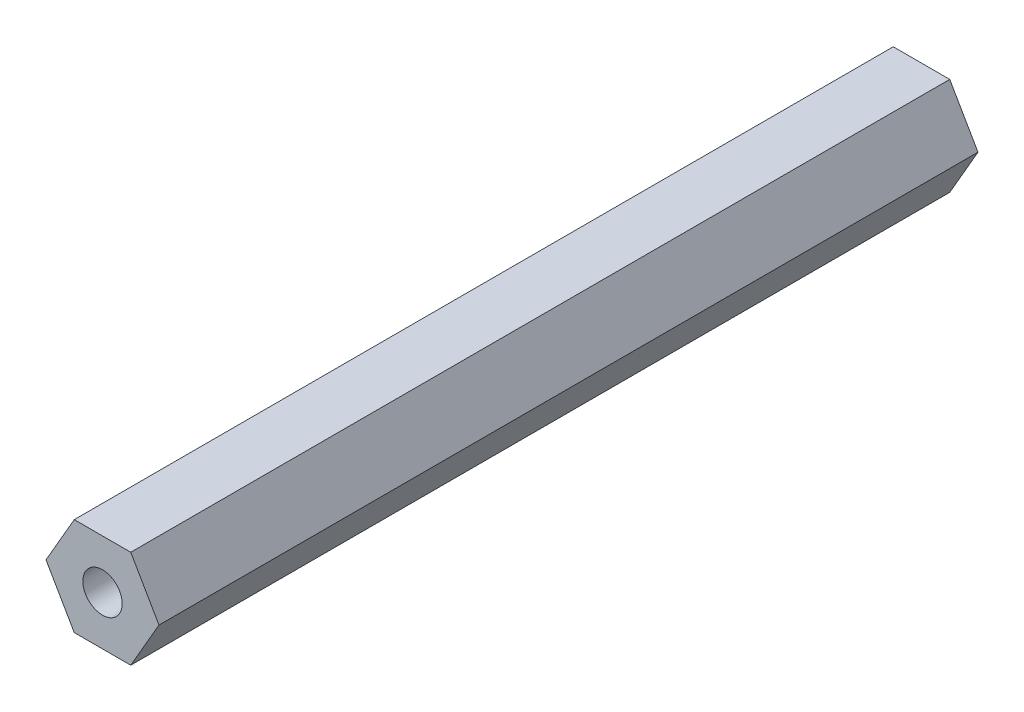
from build123d import *

# Parameters (mm, degrees)
BOSS_EXTRUDE1_DEPTH     = 106.299
F_1_4_20_TAPPED_HOLE1_D = 5.1054


with BuildPart() as part:
    # Sketch1 → Boss-Extrude1 (new body)
    with BuildSketch(Plane.XY):
        Polygon((3.666174209, -6.35), (7.332348419, 0), (3.666174209, 6.35), (-3.666174209, 6.35), (-7.332348419, 0), (-3.666174209, -6.35), align=None)
    extrude(amount=BOSS_EXTRUDE1_DEPTH)

    # 1/4-20 Tapped Hole1 (through all)
    with Locations(Plane(origin=(0, 0, 0), x_dir=(-1, 0, 0), z_dir=(0, 0, -1))):
        with Locations((0, 0)):
            Hole(F_1_4_20_TAPPED_HOLE1_D / 2)


solid = part.part
